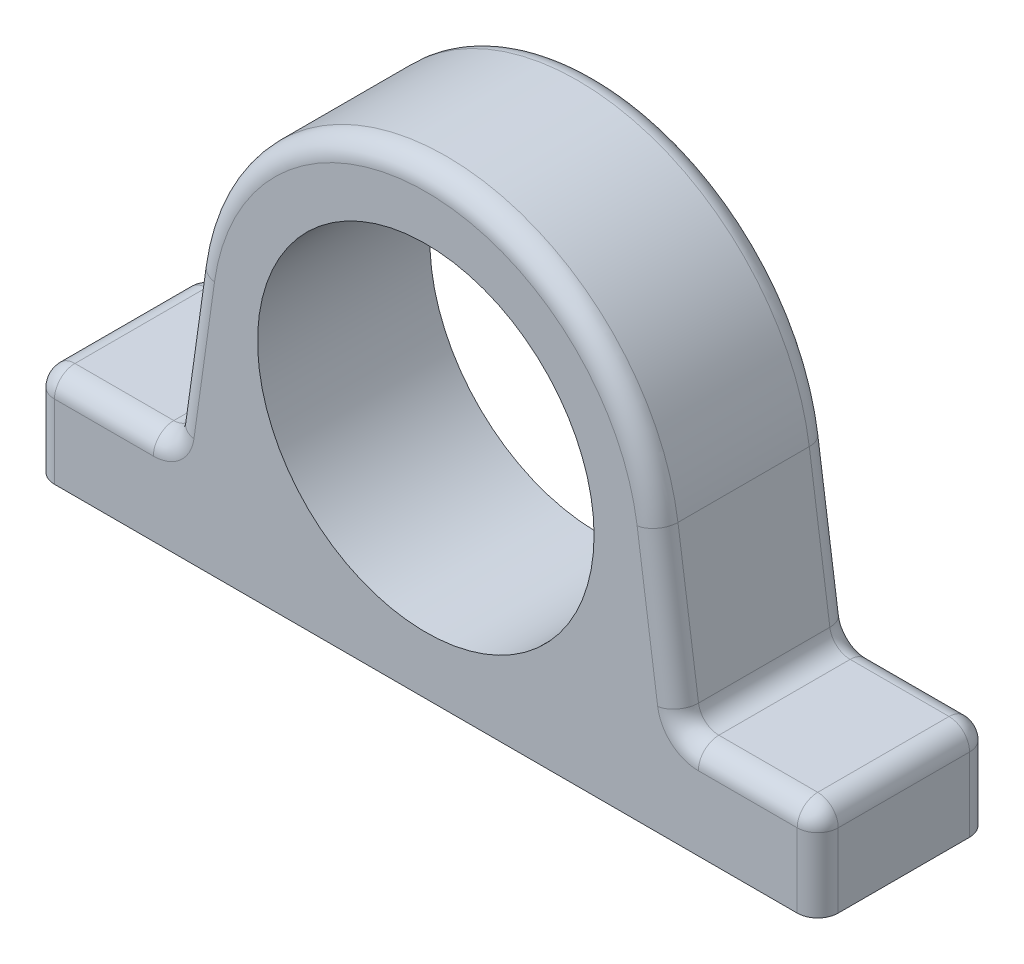
from build123d import *

# Parameters (mm, degrees)
BOSS_EXTRUDE1_DEPTH = 42
FILLET1_R           = 5


with BuildPart() as part:
    # Sketch1 → Boss-Extrude1 (new body)
    with BuildSketch(Plane.XY):
        with BuildLine():
            Line((0, 0), (-95.5, 0))
            Line((-95.5, 0), (-95.5, 23))
            Line((-95.5, 23), (-62.057478344, 23))
            Line((-62.057478344, 23), (-56.445279918, 62.932866755))
            ThreePointArc((-56.445279918, 62.932866755), (-37.395364652, 98.018446073), (0, 112))
            Line((0, 112), (0, 96))
            ThreePointArc((0, 96), (-41, 55), (0, 14))
            Line((0, 14), (0, 0))
        make_face()
    boss_extrude1 = extrude(amount=BOSS_EXTRUDE1_DEPTH)

    # Mirror1: Boss-Extrude1 across plane
    add(boss_extrude1.mirror(Plane(origin=(0, 112, 42), x_dir=(0, 0, 1), z_dir=(-1, 0, 0))))

    # Fillet1
    fillet1_edges = [part.edges().sort_by_distance(p)[0] for p in [
        (0, 112, 0),
        (-95.5, 23, 21),
        (-62.057478344, 23, 21),
        (0, 112, 42),
        (-59.251379131, 42.966433377, 42),
        (95.5, 11.5, 42),
        (-78.778739172, 23, 42),
        (78.778739172, 23, 42),
        (95.5, 23, 21),
        (59.251379131, 42.966433377, 42),
        (62.057478344, 23, 21),
        (59.251379131, 42.966433377, 0),
        (78.778739172, 23, 0),
        (-95.5, 11.5, 42),
        (95.5, 11.5, 0),
        (-95.5, 11.5, 0),
        (-78.778739172, 23, 0),
        (-59.251379131, 42.966433377, 0),
    ]]
    fillet(fillet1_edges, radius=FILLET1_R)


solid = part.part
